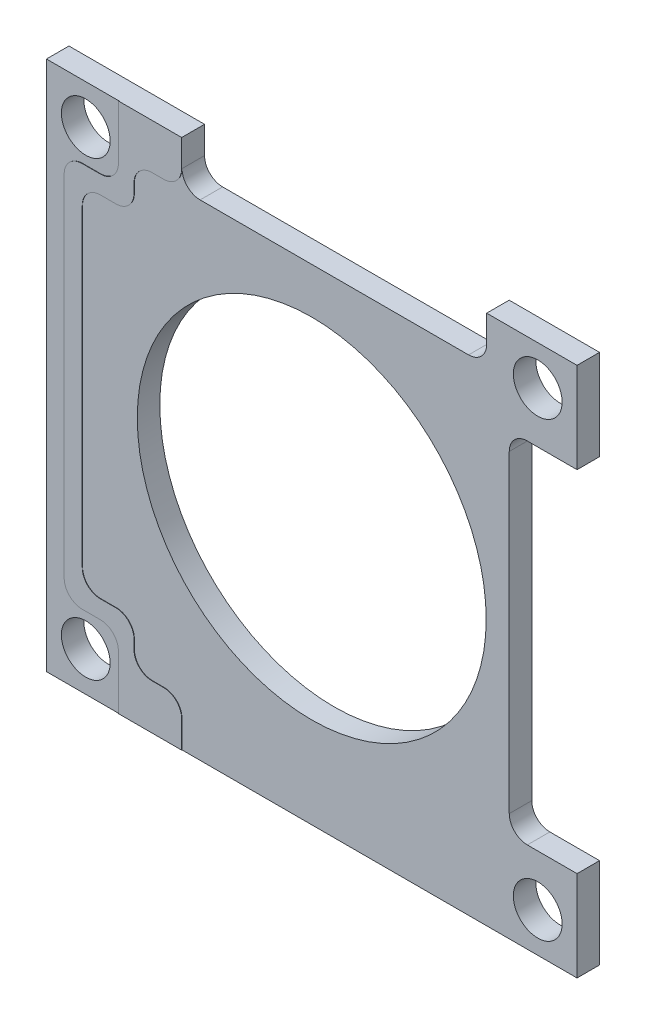
from build123d import *

# Parameters (mm, degrees)
SKETCH1_W                = 74.549
SKETCH1_H                = 74.549
SKETCH1_R                = 24.511
BOSS_EXTRUDE1_DEPTH      = 1.5748
BOSS_EXTRUDE1_DEPTH_BACK = 1.5875
SKETCH2_R                = 3.429
CUT_EXTRUDE1_DEPTH       = 4.1623
BOSS_EXTRUDE2_DEPTH      = 0.0508
FILLET3_R                = 2.54
FILLET3_OF_MIRROR3_R     = 2.54
MIRROR2_COPY_1_SKETCH_R  = 3.429
MIRROR2_COPY_1_DEPTH     = 4.1623
SKETCH14_W               = 42.799
SKETCH14_H               = 8.290530285
CUT_EXTRUDE2_DEPTH       = 4.1623
FILLET1_R                = 2.54
SKETCH17_W               = 14.315330836
SKETCH17_H               = 49.149
CUT_EXTRUDE3_DEPTH       = 4.1623
FILLET2_R                = 2.54
FILLET5_R                = 2.54


with BuildPart() as part:
    # Sketch1 → Boss-Extrude1 (new body, two sides)
    with BuildSketch(Plane.XY) as boss_extrude1_sk:
        Rectangle(SKETCH1_W, SKETCH1_H)
        Circle(SKETCH1_R, mode=Mode.SUBTRACT)
    extrude(amount=BOSS_EXTRUDE1_DEPTH)
    extrude(boss_extrude1_sk.sketch, amount=-BOSS_EXTRUDE1_DEPTH_BACK)

    # Sketch2 → Cut-Extrude1 (cut, through all)
    with BuildSketch(Plane.XY.offset(1.5748)):
        with Locations((-31.75, 31.75)):
            Circle(SKETCH2_R)
    cut_extrude1 = extrude(amount=-CUT_EXTRUDE1_DEPTH, mode=Mode.SUBTRACT)

    # Sketch20 → Boss-Extrude2 (add)
    with BuildSketch(Plane.XY.offset(1.5748)):
        Polygon((-24.921174252, 24.5745), (-24.921174252, 30.9245), (-18.2245, 30.9245), (-18.2245, 37.2745), (-27.1145, 37.2745), (-27.1145, 27.1145), (-34.7345, 27.1145), (-34.7345, 0), (-32.1945, 0), (-32.1945, 24.5745), align=None)
    boss_extrude2 = extrude(amount=BOSS_EXTRUDE2_DEPTH)

    # Fillet3
    fillet3_edges = [part.edges().sort_by_distance(p)[0] for p in [
        (-34.7345, 27.1145, 1.6002),
        (-32.1945, 24.5745, 1.6002),
        (-18.2245, 30.9245, 1.6002),
        (-24.921174252, 24.5745, 1.6002),
        (-24.921174252, 30.9245, 1.6002),
    ]]
    fillet(fillet3_edges, radius=FILLET3_R)

    # Mirror3: Boss-Extrude2 across plane
    add(boss_extrude2.mirror(Plane.ZX))

    # Fillet3 of Mirror3
    fillet3_of_mirror3_edges = [part.edges().sort_by_distance(p)[0] for p in [
        (-34.7345, -27.1145, 1.6002),
        (-32.1945, -24.5745, 1.6002),
        (-18.2245, -30.9245, 1.6002),
        (-24.921174252, -24.5745, 1.6002),
        (-24.921174252, -30.9245, 1.6002),
    ]]
    fillet(fillet3_of_mirror3_edges, radius=FILLET3_OF_MIRROR3_R)

    # Mirror1: Cut-Extrude1 across plane
    add(cut_extrude1.mirror(Plane(origin=(0, 0, 0), x_dir=(0, 0, 1), z_dir=(1, 0, 0))), mode=Mode.SUBTRACT)

    # Mirror2: Cut-Extrude1 across plane
    add(cut_extrude1.mirror(Plane.ZX), mode=Mode.SUBTRACT)

    # Mirror2 copy 1 sketch → Mirror2 copy 1 (cut, through all)
    with BuildSketch(Plane(origin=(0, 0, 1.5748), x_dir=(-1, 0, 0), z_dir=(0, 0, 1))):
        with Locations((-31.75, 31.75)):
            Circle(MIRROR2_COPY_1_SKETCH_R)
    extrude(amount=-MIRROR2_COPY_1_DEPTH, mode=Mode.SUBTRACT)

    # Sketch14 → Cut-Extrude2 (cut, through all)
    with BuildSketch(Plane.XY.offset(1.5748)):
        with Locations((3.175, 35.069765143)):
            Rectangle(SKETCH14_W, SKETCH14_H)
    extrude(amount=-CUT_EXTRUDE2_DEPTH, mode=Mode.SUBTRACT)

    # Fillet1
    fillet1_edges = [part.edges().sort_by_distance(p)[0] for p in [
        (-18.2245, 30.9245, -0.00635),
        (24.5745, 30.9245, -0.00635),
    ]]
    fillet(fillet1_edges, radius=FILLET1_R)

    # Sketch17 → Cut-Extrude3 (cut, through all)
    with BuildSketch(Plane.XY.offset(1.5748)):
        with Locations((34.907165418, 0)):
            Rectangle(SKETCH17_W, SKETCH17_H)
    extrude(amount=-CUT_EXTRUDE3_DEPTH, mode=Mode.SUBTRACT)

    # Fillet2
    fillet2_edges = [part.edges().sort_by_distance(p)[0] for p in [
        (27.7495, -24.5745, -0.00635),
        (27.7495, 24.5745, -0.00635),
    ]]
    fillet(fillet2_edges, radius=FILLET2_R)

    # Fillet5
    fillet5_edges = [part.edges().sort_by_distance(p)[0] for p in [
        (-27.1145, -27.1145, 1.6002),
        (-27.1145, 27.1145, 1.6002),
    ]]
    fillet(fillet5_edges, radius=FILLET5_R)


solid = part.part
